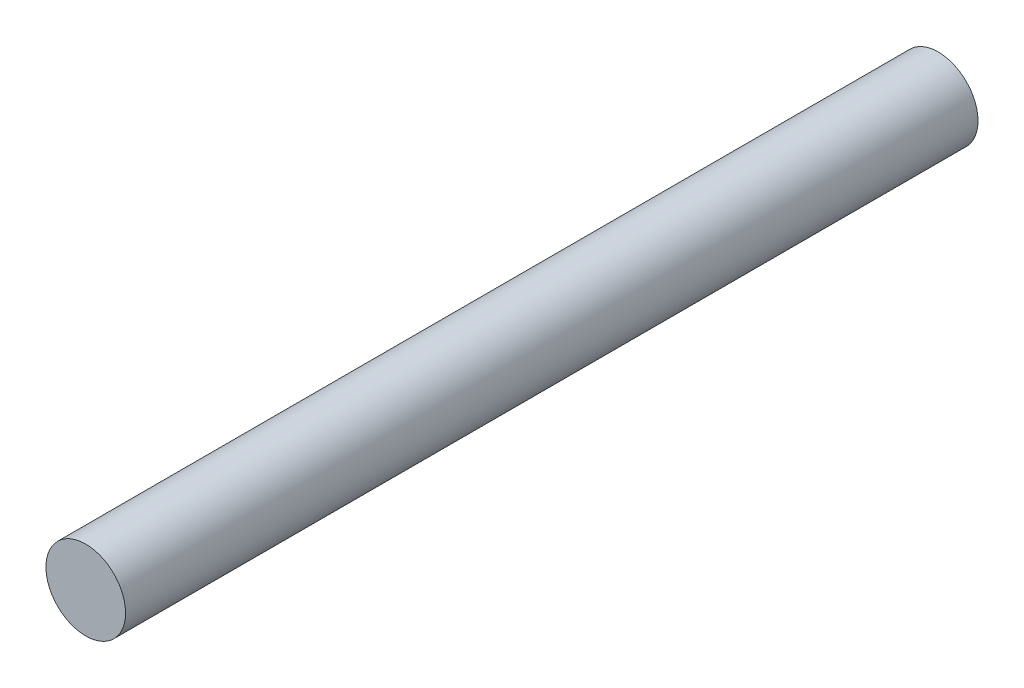
from build123d import *

# Parameters (mm, degrees)
SKETCH1_R           = 3
BOSS_EXTRUDE1_DEPTH = 64.24


with BuildPart() as part:
    # Sketch1 → Boss-Extrude1 (new body)
    with BuildSketch(Plane.XY):
        with Locations((-139.011827936, -69.82998441)):
            Circle(SKETCH1_R)
    extrude(amount=BOSS_EXTRUDE1_DEPTH)


solid = part.part
